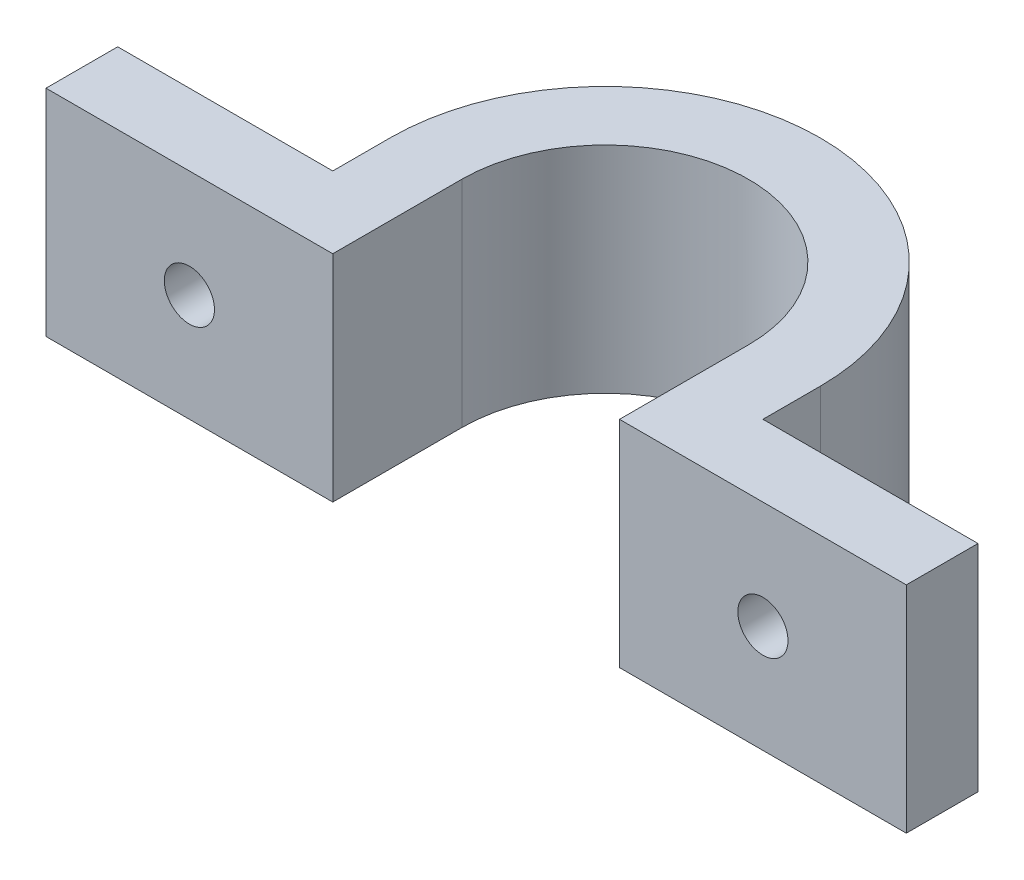
from build123d import *

# Parameters (mm, degrees)
BOSS_EXTRUDE1_DEPTH = 15
SKETCH2_R           = 1.75
CUT_EXTRUDE1_DEPTH  = 6


with BuildPart() as part:
    # Sketch1 → Boss-Extrude1 (new body)
    with BuildSketch(Plane(origin=(0, 0, 0), x_dir=(1, 0, 0), z_dir=(0, 1, 0))):
        with BuildLine():
            Line((-30, -4), (-30, -9))
            Line((-30, -9), (-10, -9))
            Line((-10, -9), (-10, 0))
            ThreePointArc((-10, 0), (0, 10), (10, 0))
            Line((10, 0), (10, -9))
            Line((10, -9), (30, -9))
            Line((30, -9), (30, -4))
            Line((30, -4), (15, -4))
            Line((15, -4), (15, 0))
            ThreePointArc((15, 0), (0, 15), (-15, 0))
            Line((-15, 0), (-15, -4))
            Line((-15, -4), (-30, -4))
        make_face()
    extrude(amount=BOSS_EXTRUDE1_DEPTH)

    # Sketch2 → Cut-Extrude1 (cut, through all)
    with BuildSketch(Plane(origin=(0, 0, 4), x_dir=(-1, 0, 0), z_dir=(0, 0, -1))):
        with Locations((-20, 7.5)):
            Circle(SKETCH2_R)
        with Locations((20, 7.5)):
            Circle(SKETCH2_R)
    extrude(amount=-CUT_EXTRUDE1_DEPTH, mode=Mode.SUBTRACT)


solid = part.part
